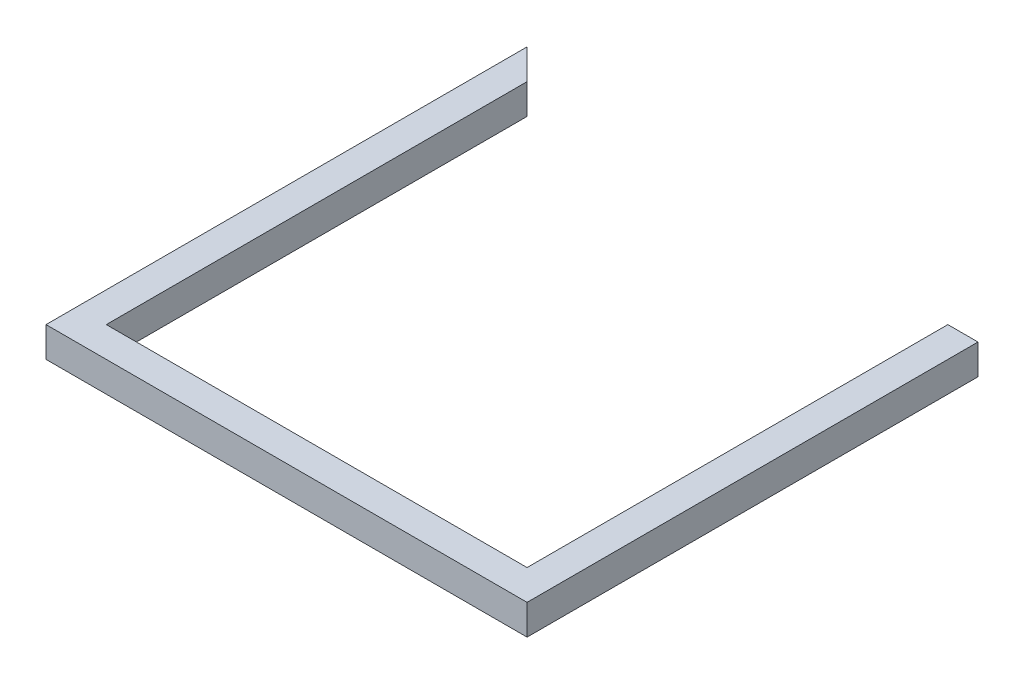
from build123d import *

# Parameters (mm, degrees)
BOSS_EXTRUDE1_DEPTH = 25
SHELL1_T            = -3


with BuildPart() as part:
    # Sketch1 → Boss-Extrude1 (new body)
    with BuildSketch(Plane(origin=(0, 0, 0), x_dir=(1, 0, 0), z_dir=(0, 1, 0))):
        Polygon((-174.5, 174.5), (-174.5, -174.5), (174.5, -174.5), (174.5, 174.5), (199.5, 174.5), (199.5, -199.5), (-199.5, -199.5), (-199.5, 199.5), align=None)
    extrude(amount=BOSS_EXTRUDE1_DEPTH)

    # Shell1
    shell1_openings = [part.faces().sort_by_distance(p)[0] for p in [
        (187, 12.5, -174.5),
        (-187, 12.5, -187),
    ]]
    offset(amount=SHELL1_T, openings=shell1_openings, kind=Kind.INTERSECTION)


solid = part.part
